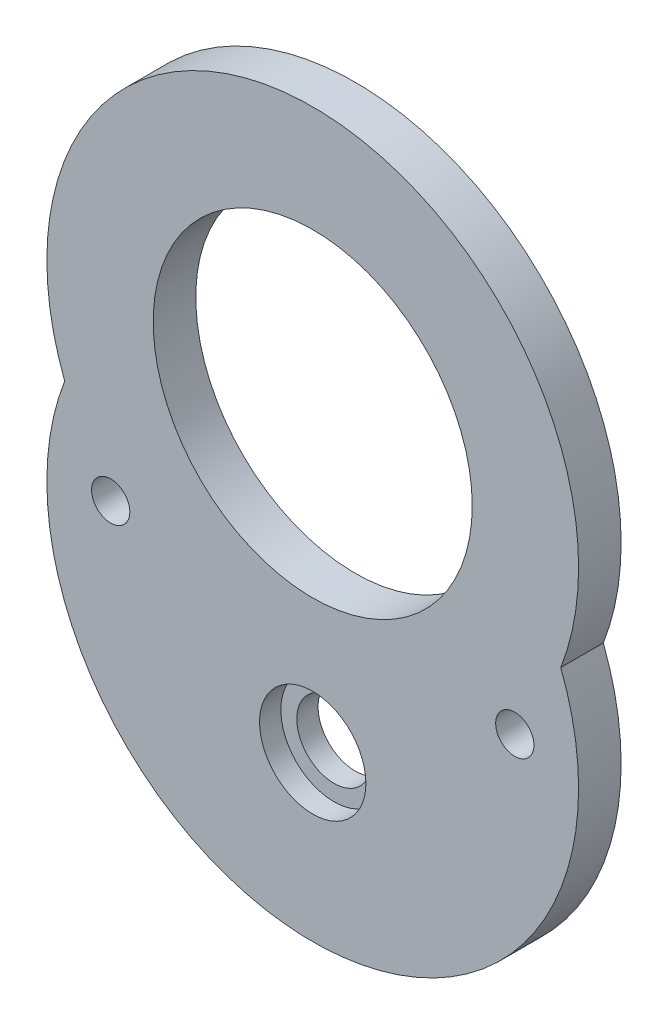
from build123d import *

# Parameters (mm, degrees)
SKETCH_1_R          = 7.5
SKETCH_1_R_2        = 1.75
SKETCH_1_R_3        = 0.9
EXTRUDE_1_DEPTH     = 2
SKETCH_2_R          = 2.5
CUT_EXTRUDE_1_DEPTH = 1


with BuildPart() as part:
    # 草图1 → 凸台-拉伸1 (new body)
    with BuildSketch(Plane.XY):
        with BuildLine():
            ThreePointArc((11.66190379, -4.5), (0, 12.5), (-11.66190379, -4.5))
            ThreePointArc((-11.66190379, -4.5), (0, -21.5), (11.66190379, -4.5))
        make_face()
        Circle(SKETCH_1_R, mode=Mode.SUBTRACT)
        with Locations((0, -13.8)):
            Circle(SKETCH_1_R_2, mode=Mode.SUBTRACT)
        with Locations((-9.5, -8.3)):
            Circle(SKETCH_1_R_3, mode=Mode.SUBTRACT)
        with Locations((9.5, -8.3)):
            Circle(SKETCH_1_R_3, mode=Mode.SUBTRACT)
    extrude(amount=EXTRUDE_1_DEPTH)

    # 草图2 → 切除-拉伸1 (cut)
    with BuildSketch(Plane.XY.offset(2)):
        with Locations((0, -13.8)):
            Circle(SKETCH_2_R)
    extrude(amount=-CUT_EXTRUDE_1_DEPTH, mode=Mode.SUBTRACT)


solid = part.part
